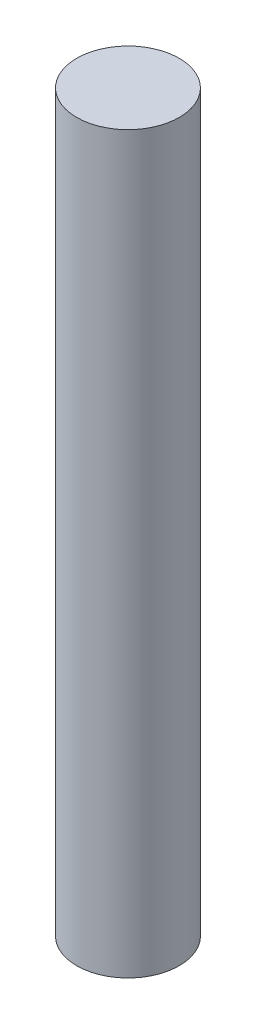
from build123d import *

# Parameters (mm, degrees)
SKETCH1_R           = 3
BOSS_EXTRUDE1_DEPTH = 43


with BuildPart() as part:
    # Sketch1 → Boss-Extrude1 (new body)
    with BuildSketch(Plane(origin=(0, 0, 0), x_dir=(1, 0, 0), z_dir=(0, 1, 0))):
        with Locations(Location((0, 0, 0), (0, 0, 270))):  # turned: the seam where the file's is
            Circle(SKETCH1_R)
    extrude(amount=BOSS_EXTRUDE1_DEPTH)


solid = part.part
